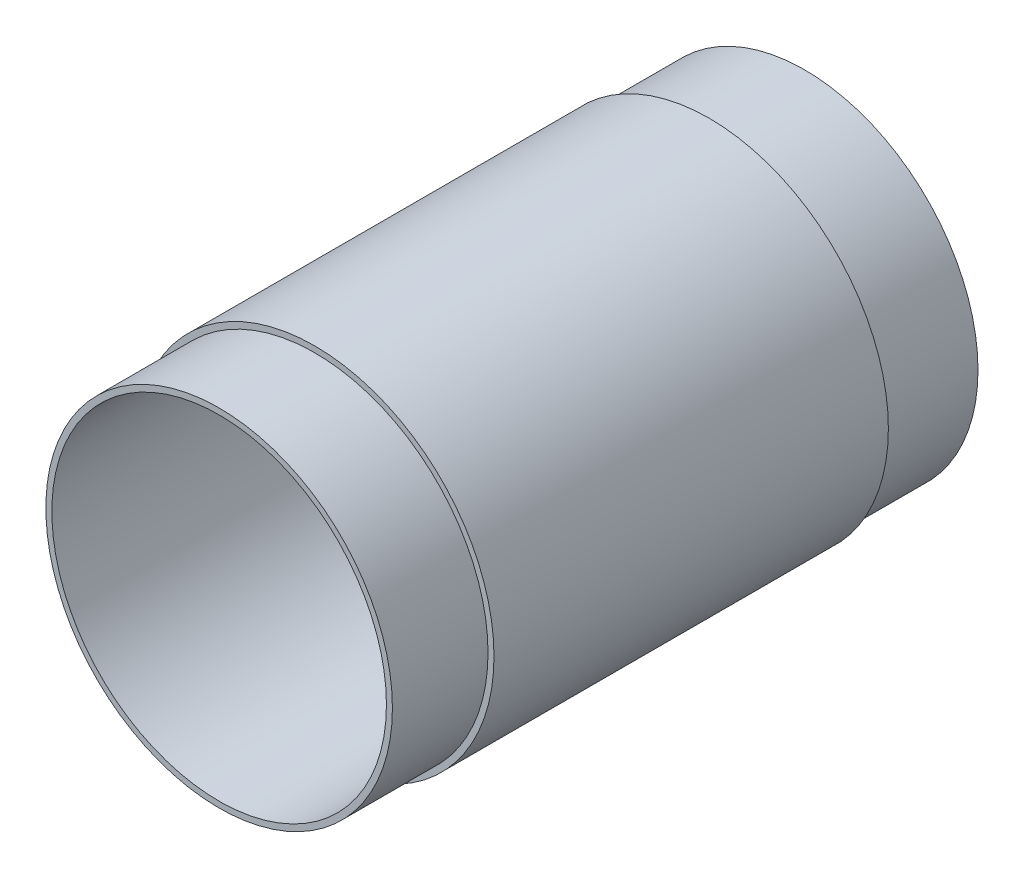
from build123d import *


with BuildPart() as part:
    # Sketch1 → Revolve1 (revolve)
    with BuildSketch(Plane(origin=(0, 0, 0), x_dir=(0, 0, -1), z_dir=(1, 0, 0))):
        Polygon((0, 14), (49, 14), (49, 14.5), (41, 14.5), (41, 15), (8, 15), (8, 14.5), (0, 14.5), align=None)
    revolve(axis=Axis((0, 0, 0), (0, 0, -1)))


solid = part.part
